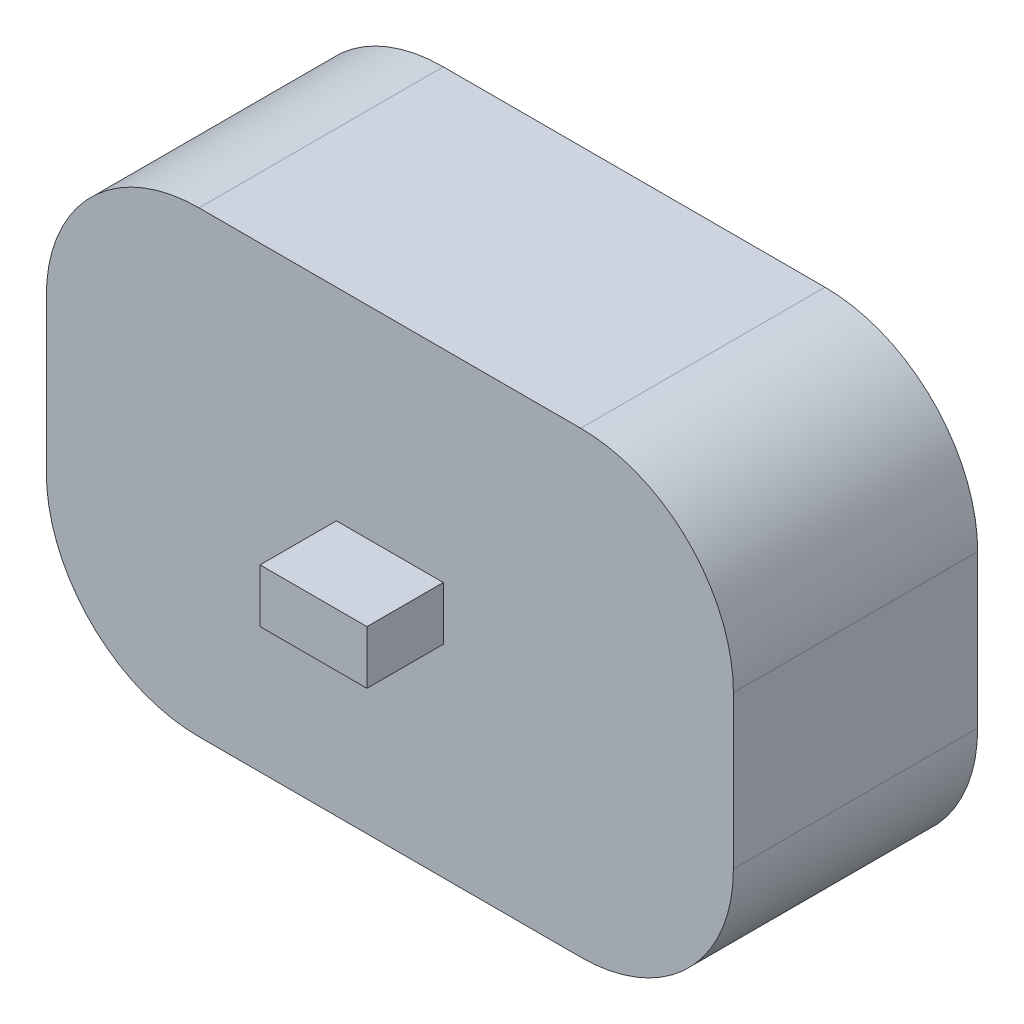
from build123d import *

# Parameters (mm, degrees)
SKETCH1_W           = 45
SKETCH1_H           = 30
BOSS_EXTRUDE1_DEPTH = 16
SKETCH2_W           = 7
SKETCH2_H           = 3.5
BOSS_EXTRUDE2_DEPTH = 5
FILLET1_R           = 10


with BuildPart() as part:
    # Sketch1 → Boss-Extrude1 (new body)
    with BuildSketch(Plane.XY):
        Rectangle(SKETCH1_W, SKETCH1_H)
    extrude(amount=BOSS_EXTRUDE1_DEPTH)

    # Sketch2 → Boss-Extrude2 (add)
    with BuildSketch(Plane.XY.offset(16)):
        Rectangle(SKETCH2_W, SKETCH2_H)
    extrude(amount=BOSS_EXTRUDE2_DEPTH)

    # Fillet1
    fillet1_edges = [part.edges().sort_by_distance(p)[0] for p in [
        (22.5, -15, 8),
        (-22.5, -15, 8),
        (-22.5, 15, 8),
        (22.5, 15, 8),
    ]]
    fillet(fillet1_edges, radius=FILLET1_R)


solid = part.part
